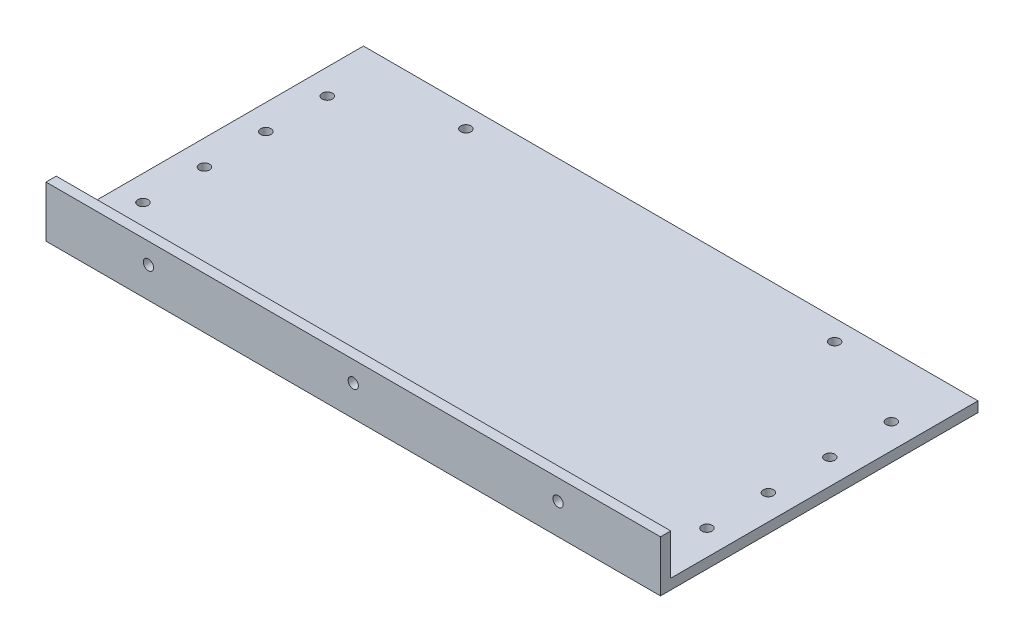
from build123d import *

# Parameters (mm, degrees)
SKETCH1_W           = 381
SKETCH1_H           = 190.5
BOSS_EXTRUDE1_DEPTH = 6.35
SKETCH2_W           = 381
SKETCH2_H           = 31.75
BOSS_EXTRUDE2_DEPTH = 6.35
SKETCH3_R           = 3.175
CUT_EXTRUDE1_DEPTH  = 6.35
SKETCH4_R           = 3.175
CUT_EXTRUDE2_DEPTH  = 6.35
SKETCH5_R           = 3.175
CUT_EXTRUDE3_DEPTH  = 6.35


with BuildPart() as part:
    # Sketch1 → Boss-Extrude1 (new body)
    with BuildSketch(Plane(origin=(0, 0, 0), x_dir=(1, 0, 0), z_dir=(0, 1, 0))):
        Rectangle(SKETCH1_W, SKETCH1_H)
    extrude(amount=BOSS_EXTRUDE1_DEPTH)

    # Sketch2 → Boss-Extrude2 (add)
    with BuildSketch(Plane.XY.offset(95.25)):
        with Locations((0, 15.875)):
            Rectangle(SKETCH2_W, SKETCH2_H)
    extrude(amount=BOSS_EXTRUDE2_DEPTH)

    # Sketch3 → Cut-Extrude1 (cut)
    with BuildSketch(Plane.XY.offset(101.6)):
        with Locations((0, 19.05)):
            Circle(SKETCH3_R)
        with Locations((-127, 19.05)):
            Circle(SKETCH3_R)
        with Locations((127, 19.05)):
            Circle(SKETCH3_R)
    extrude(amount=-CUT_EXTRUDE1_DEPTH, mode=Mode.SUBTRACT)

    # Sketch4 → Cut-Extrude2 (cut)
    with BuildSketch(Plane.XZ):
        with Locations((0, 82.55)):
            Circle(SKETCH4_R)
        with Locations((-114.3, 82.55)):
            Circle(SKETCH4_R)
        with Locations((114.3, 82.55)):
            Circle(SKETCH4_R)
        with Locations((-114.3, -82.55)):
            Circle(SKETCH4_R)
        with Locations((114.3, -82.55)):
            Circle(SKETCH4_R)
    extrude(amount=-CUT_EXTRUDE2_DEPTH, mode=Mode.SUBTRACT)

    # Sketch5 → Cut-Extrude3 (cut)
    with BuildSketch(Plane.XZ):
        with Locations((174.8536, 57.15)):
            Circle(SKETCH5_R)
        with Locations((174.8536, 19.05)):
            Circle(SKETCH5_R)
        with Locations((174.8536, -19.05)):
            Circle(SKETCH5_R)
        with Locations((174.8536, -57.15)):
            Circle(SKETCH5_R)
        with Locations((-174.8536, -57.15)):
            Circle(SKETCH5_R)
        with Locations((-174.8536, -19.05)):
            Circle(SKETCH5_R)
        with Locations((-174.8536, 19.05)):
            Circle(SKETCH5_R)
        with Locations((-174.8536, 57.15)):
            Circle(SKETCH5_R)
    extrude(amount=-CUT_EXTRUDE3_DEPTH, mode=Mode.SUBTRACT)


solid = part.part
